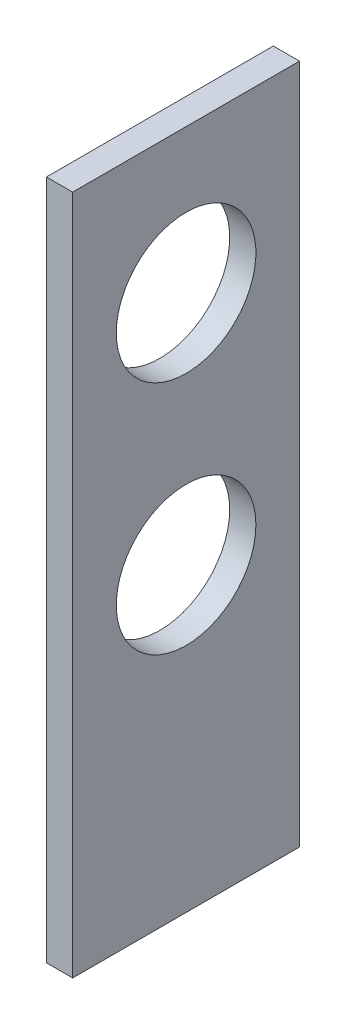
from build123d import *

# Parameters (mm, degrees)
CROQUIS1_W              = 26
CROQUIS1_H              = 78
SALIENTE_EXTRUIR1_DEPTH = 3
CROQUIS2_R              = 8
CORTAR_EXTRUIR1_DEPTH   = 4


with BuildPart() as part:
    # Croquis1 → Saliente-Extruir1 (new body)
    with BuildSketch(Plane(origin=(0, 0, 0), x_dir=(0, 0, -1), z_dir=(1, 0, 0))):
        with Locations((-13, 39)):
            Rectangle(CROQUIS1_W, CROQUIS1_H)
    extrude(amount=SALIENTE_EXTRUIR1_DEPTH)

    # Croquis2 → Cortar-Extruir1 (cut, through all)
    with BuildSketch(Plane.ZY):
        with Locations((13, 61.5)):
            Circle(CROQUIS2_R)
        with Locations((13, 34.5)):
            Circle(CROQUIS2_R)
    extrude(amount=-CORTAR_EXTRUIR1_DEPTH, mode=Mode.SUBTRACT)


solid = part.part
